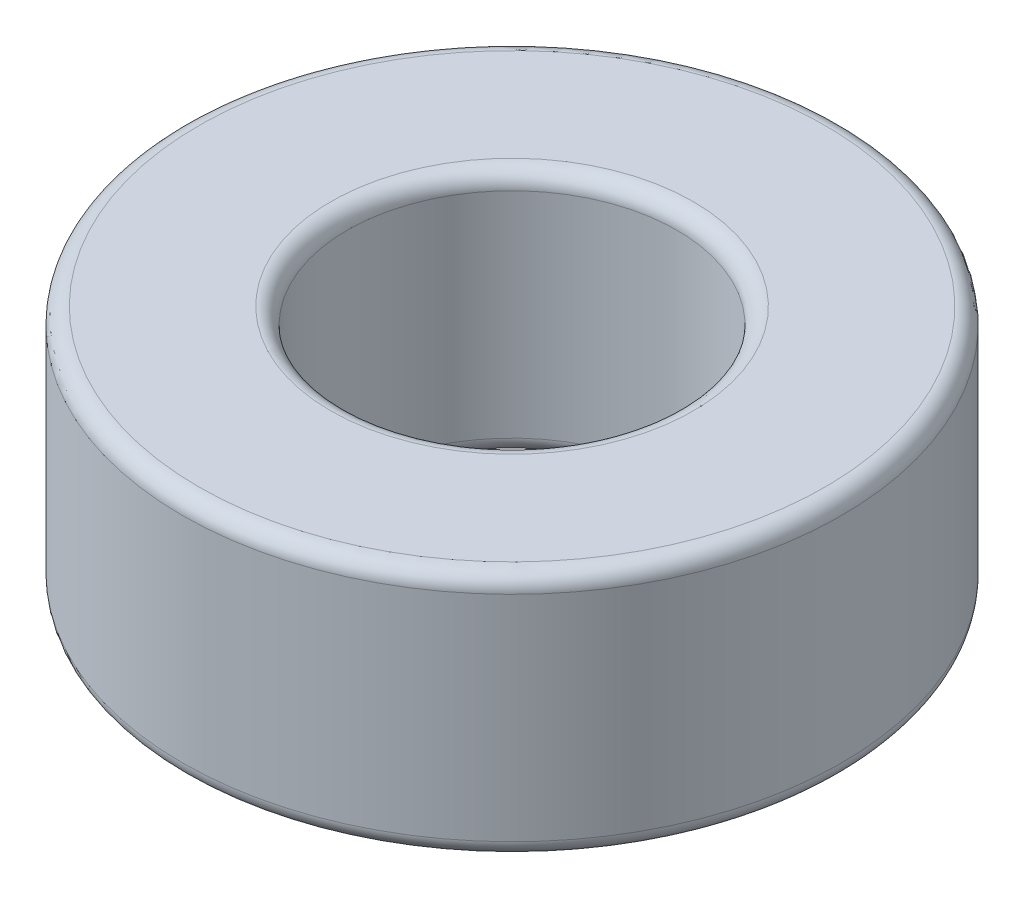
from build123d import *

# Parameters (mm, degrees)
SKETCH1_R           = 20
SKETCH1_R_2         = 10
BOSS_EXTRUDE2_DEPTH = 15
FILLET1_R           = 1
FILLET2_R           = 1
FILLET3_R           = 1


with BuildPart() as part:
    # Sketch1 → Boss-Extrude2 (new body)
    with BuildSketch(Plane(origin=(0, 0, 0), x_dir=(1, 0, 0), z_dir=(0, 1, 0))):
        Circle(SKETCH1_R)
        Circle(SKETCH1_R_2, mode=Mode.SUBTRACT)
    extrude(amount=BOSS_EXTRUDE2_DEPTH)

    # Fillet1
    fillet1_edges = [part.edges().sort_by_distance(p)[0] for p in [
        (-20, 15, 0),
    ]]
    fillet(fillet1_edges, radius=FILLET1_R)

    # Fillet2
    fillet2_edges = [part.edges().sort_by_distance(p)[0] for p in [
        (-10, 15, 0),
    ]]
    fillet(fillet2_edges, radius=FILLET2_R)

    # Fillet3
    fillet3_edges = [part.edges().sort_by_distance(p)[0] for p in [
        (-20, 0, 0),
        (-10, 0, 0),
    ]]
    fillet(fillet3_edges, radius=FILLET3_R)


solid = part.part
